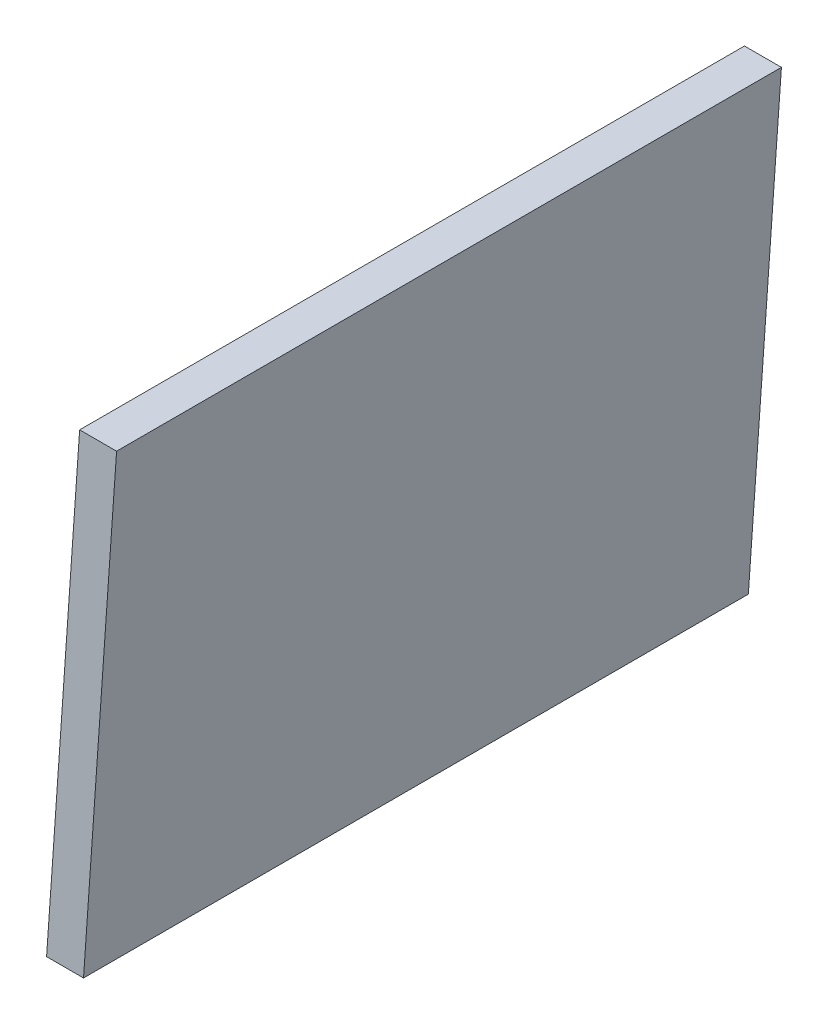
from build123d import *

# Parameters (mm, degrees)
BOSS_EXTRUDE1_DEPTH = 450


with BuildPart() as part:
    # Sketch1 → Boss-Extrude1 (new body)
    with BuildSketch(Plane.XY):
        Polygon((0, 0), (22.376579822, 320), (47.376579822, 320), (25, 0), align=None)
    extrude(amount=BOSS_EXTRUDE1_DEPTH)


solid = part.part
